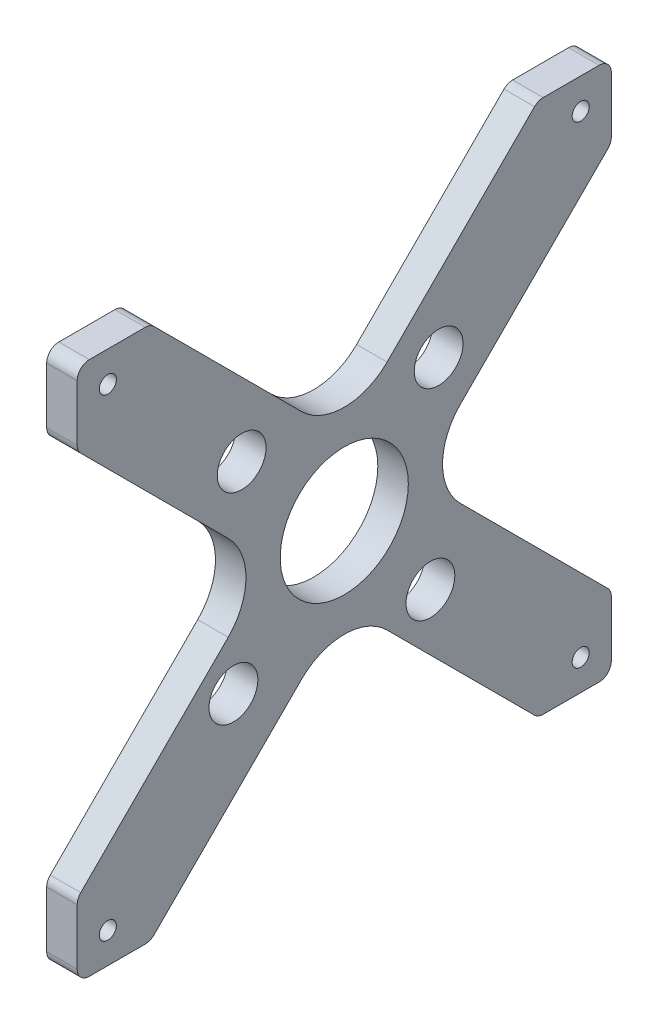
from build123d import *

# Parameters (mm, degrees)
BOSS_EXTRUDE1_DEPTH = 6.35
SKETCH1_9_R         = 13.335
CUT_EXTRUDE1_DEPTH  = 11.938
SKETCH1_10_R        = 1.778
CUT_EXTRUDE2_DEPTH  = 24.638
SKETCH1_11_R        = 1.778
CUT_EXTRUDE3_DEPTH  = 24.13
SKETCH1_12_R        = 1.778
CUT_EXTRUDE4_DEPTH  = 38.862
SKETCH1_13_R        = 1.778
CUT_EXTRUDE5_DEPTH  = 13.462
FILLET1_R           = 2.54
SKETCH2_R           = 5.08
CUT_EXTRUDE6_DEPTH  = 13.462


with BuildPart() as part:
    # Sketch1 → Boss-Extrude1 (new body)
    with BuildSketch(Plane(origin=(0, 0, 0), x_dir=(0, 0, -1), z_dir=(1, 0, 0))):
        with BuildLine():
            Line((-53.874845122, 46.825199553), (-38.634845122, 46.825199553))
            Line((-38.634845122, 46.825199553), (-7.203948698, 15.394303129))
            ThreePointArc((-7.203948698, 15.394303129), (1.709004986, 11.702436832), (10.621958671, 15.394303129))
            Line((10.621958671, 15.394303129), (42.052855095, 46.825199553))
            Line((42.052855095, 46.825199553), (57.292855095, 46.825199553))
            Line((57.292855095, 46.825199553), (57.292855095, 31.585199553))
            Line((57.292855095, 31.585199553), (25.861958671, 0.154303129))
            ThreePointArc((25.861958671, 0.154303129), (22.170092374, -8.758650555), (25.861958671, -17.67160424))
            Line((25.861958671, -17.67160424), (57.292855095, -49.102500664))
            Line((57.292855095, -49.102500664), (57.292855095, -64.342500664))
            Line((57.292855095, -64.342500664), (42.052855095, -64.342500664))
            Line((42.052855095, -64.342500664), (10.621958671, -32.91160424))
            ThreePointArc((10.621958671, -32.91160424), (1.709004986, -29.219737943), (-7.203948698, -32.91160424))
            Line((-7.203948698, -32.91160424), (-38.634845122, -64.342500664))
            Line((-38.634845122, -64.342500664), (-53.874845122, -64.342500664))
            Line((-53.874845122, -64.342500664), (-53.874845122, -49.102500664))
            Line((-53.874845122, -49.102500664), (-22.443948698, -17.67160424))
            ThreePointArc((-22.443948698, -17.67160424), (-18.752082401, -8.758650555), (-22.443948698, 0.154303129))
            Line((-22.443948698, 0.154303129), (-53.874845122, 31.585199553))
            Line((-53.874845122, 31.585199553), (-53.874845122, 46.825199553))
        make_face()
    extrude(amount=BOSS_EXTRUDE1_DEPTH)

    # Sketch1_9 → Cut-Extrude1 (cut)
    with BuildSketch(Plane(origin=(0, 0, 0), x_dir=(0, 0, -1), z_dir=(1, 0, 0))):
        with Locations((1.709004986, -8.758650555)):
            Circle(SKETCH1_9_R)
    extrude(amount=CUT_EXTRUDE1_DEPTH, mode=Mode.SUBTRACT)

    # Sketch1_10 → Cut-Extrude2 (cut)
    with BuildSketch(Plane(origin=(0, 0, 0), x_dir=(0, 0, -1), z_dir=(1, 0, 0))):
        with Locations((-47.503495014, -57.971150555)):
            Circle(SKETCH1_10_R)
    extrude(amount=CUT_EXTRUDE2_DEPTH, mode=Mode.SUBTRACT)

    # Sketch1_11 → Cut-Extrude3 (cut)
    with BuildSketch(Plane(origin=(0, 0, 0), x_dir=(0, 0, -1), z_dir=(1, 0, 0))):
        with Locations((50.921504986, -57.971150555)):
            Circle(SKETCH1_11_R)
    extrude(amount=CUT_EXTRUDE3_DEPTH, mode=Mode.SUBTRACT)

    # Sketch1_12 → Cut-Extrude4 (cut)
    with BuildSketch(Plane(origin=(0, 0, 0), x_dir=(0, 0, -1), z_dir=(1, 0, 0))):
        with Locations((50.921504986, 40.453849445)):
            Circle(SKETCH1_12_R)
    extrude(amount=CUT_EXTRUDE4_DEPTH, mode=Mode.SUBTRACT)

    # Sketch1_13 → Cut-Extrude5 (cut)
    with BuildSketch(Plane(origin=(0, 0, 0), x_dir=(0, 0, -1), z_dir=(1, 0, 0))):
        with Locations((-47.503495014, 40.453849445)):
            Circle(SKETCH1_13_R)
    extrude(amount=CUT_EXTRUDE5_DEPTH, mode=Mode.SUBTRACT)

    # Fillet1
    fillet1_edges = [part.edges().sort_by_distance(p)[0] for p in [
        (3.175, 46.825199553, 53.874845122),
        (3.175, 46.825199553, 38.634845122),
        (3.175, 46.825199553, -42.052855095),
        (3.175, 46.825199553, -57.292855095),
        (3.175, 31.585199553, -57.292855095),
        (3.175, -49.102500664, -57.292855095),
        (3.175, -64.342500664, -57.292855095),
        (3.175, -64.342500664, -42.052855095),
        (3.175, -64.342500664, 38.634845122),
        (3.175, -64.342500664, 53.874845122),
        (3.175, -49.102500664, 53.874845122),
        (3.175, 31.585199553, 53.874845122),
    ]]
    fillet(fillet1_edges, radius=FILLET1_R)

    # Sketch2 → Cut-Extrude6 (cut)
    with BuildSketch(Plane.ZY):
        with Locations((-21.351416825, 10.883761284)):
            Circle(SKETCH2_R)
        with Locations((19.642411839, 12.59276627)):
            Circle(SKETCH2_R)
        with Locations((21.351416825, -28.401062394)):
            Circle(SKETCH2_R)
        with Locations((-19.642411839, -30.110067381)):
            Circle(SKETCH2_R)
    extrude(amount=-CUT_EXTRUDE6_DEPTH, mode=Mode.SUBTRACT)


solid = part.part
